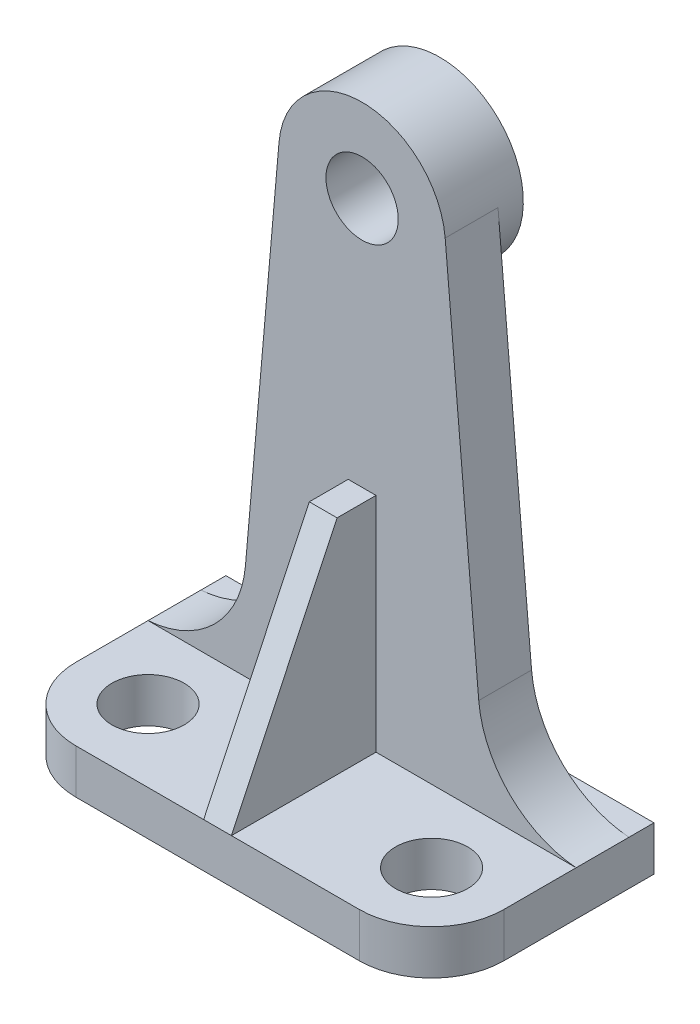
from build123d import *

# Parameters (mm, degrees)
EXTRUDE_1_DEPTH     = 8
SKETCH_2_R          = 6.5
CUT_EXTRUDE_1_DEPTH = 8
EXTRUDE_2_DEPTH     = 9.5
SKETCH_4_R          = 15
EXTRUDE_3_DEPTH     = 4.5
SKETCH_5_R          = 6.5
CUT_EXTRUDE_2_DEPTH = 41
EXTRUDE_4_DEPTH     = 2.5


with BuildPart() as part:
    # 스케치1 → 보스-돌출1 (new body)
    with BuildSketch(Plane(origin=(0, 0, 0), x_dir=(1, 0, 0), z_dir=(0, 1, 0))):
        with BuildLine():
            Line((-38.5, 40), (38.5, 40))
            Line((38.5, 40), (38.5, 13))
            ThreePointArc((38.5, 13), (34.692388155, 3.807611845), (25.5, 0))
            Line((25.5, 0), (-25.5, 0))
            ThreePointArc((-25.5, 0), (-34.692388155, 3.807611845), (-38.5, 13))
            Line((-38.5, 13), (-38.5, 40))
        make_face()
    extrude(amount=EXTRUDE_1_DEPTH)

    # 스케치2 → 컷-돌출1 (cut)
    with BuildSketch(Plane(origin=(0, 8, 0), x_dir=(1, 0, 0), z_dir=(0, 1, 0))):
        with Locations((-25.5, 13)):
            Circle(SKETCH_2_R)
        with Locations((25.5, 13)):
            Circle(SKETCH_2_R)
    extrude(amount=-CUT_EXTRUDE_1_DEPTH, mode=Mode.SUBTRACT)

    # 스케치3 → 보스-돌출2 (add)
    with BuildSketch(Plane(origin=(0, 0, -26), x_dir=(-1, 0, 0), z_dir=(0, 0, -1))):
        with BuildLine():
            Line((-38.5, 0), (-38.5, 8))
            ThreePointArc((-38.5, 8), (-26.561663341, 13.425258865), (-20.981002143, 25.291746827))
            Line((-20.981002143, 25.291746827), (-14.942920471, 94.307336141))
            ThreePointArc((-14.942920471, 94.307336141), (0, 108), (14.942920471, 94.307336141))
            Line((14.942920471, 94.307336141), (20.981002143, 25.291746827))
            ThreePointArc((20.981002143, 25.291746827), (26.561663341, 13.425258865), (38.5, 8))
            Line((38.5, 8), (38.5, 0))
            Line((38.5, 0), (-38.5, 0))
        make_face()
    extrude(amount=EXTRUDE_2_DEPTH)

    # 스케치4 → 보스-돌출3 (add)
    with BuildSketch(Plane(origin=(0, 0, -35.5), x_dir=(-1, 0, 0), z_dir=(0, 0, -1))):
        with Locations((0, 93)):
            Circle(SKETCH_4_R)
    extrude(amount=EXTRUDE_3_DEPTH)

    # 스케치5 → 컷-돌출2 (cut, through all)
    with BuildSketch(Plane(origin=(0, 0, -40), x_dir=(-1, 0, 0), z_dir=(0, 0, -1))):
        with Locations((0, 93)):
            Circle(SKETCH_5_R)
    extrude(amount=-CUT_EXTRUDE_2_DEPTH, mode=Mode.SUBTRACT)

    # 스케치7 → 보스-돌출4 (add, symmetric)
    with BuildSketch(Plane(origin=(0, 0, 0), x_dir=(0, 0, -1), z_dir=(1, 0, 0))):
        Polygon((0, 8), (35.5, 8), (35.5, 48), (19, 48), align=None)
    extrude(amount=EXTRUDE_4_DEPTH, both=True)


solid = part.part
